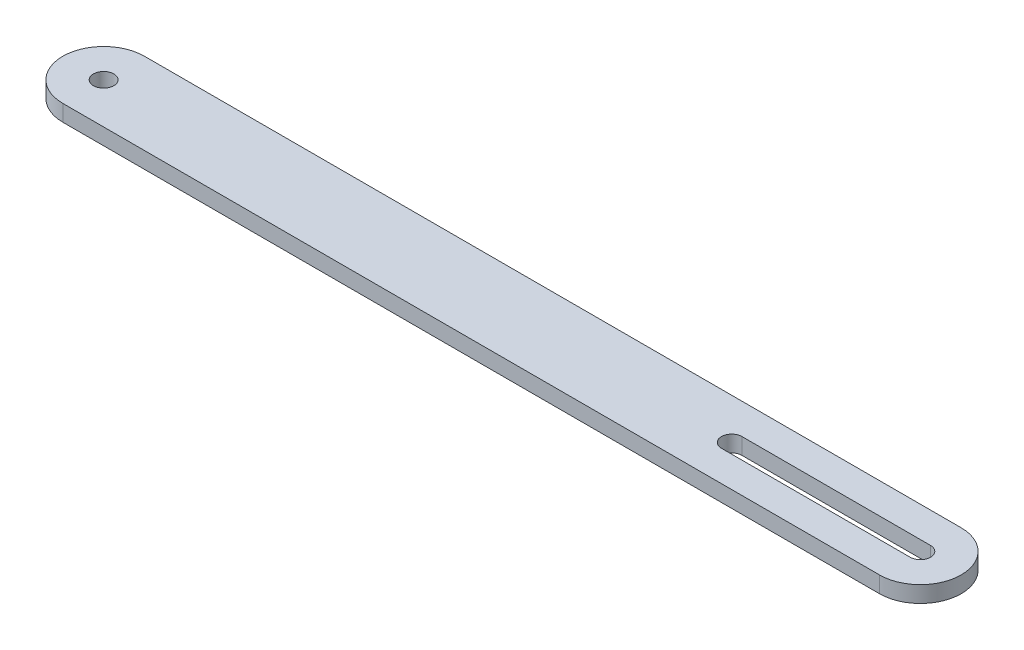
from build123d import *

# Parameters (mm, degrees)
SKETCH1_R           = 12.5
BOSS_EXTRUDE2_DEPTH = 20


with BuildPart() as part:
    # Sketch1 → Boss-Extrude2 (new body)
    with BuildSketch(Plane(origin=(0, 0, 0), x_dir=(1, 0, 0), z_dir=(0, 1, 0))):
        with BuildLine():
            Line((500, 50), (-500, 50))
            ThreePointArc((-500, 50), (-550, 0), (-500, -50))
            Line((-500, -50), (500, -50))
            ThreePointArc((500, -50), (550, 0), (500, 50))
        make_face()
        with Locations((-500, 0)):
            Circle(SKETCH1_R, mode=Mode.SUBTRACT)
        with BuildLine():
            ThreePointArc((269, -12.5), (256.5, 0), (269, 12.5))
            Line((269, 12.5), (500, 12.5))
            ThreePointArc((500, 12.5), (512.5, 0), (500, -12.5))
            Line((500, -12.5), (269, -12.5))
        make_face(mode=Mode.SUBTRACT)
    extrude(amount=BOSS_EXTRUDE2_DEPTH)


solid = part.part
